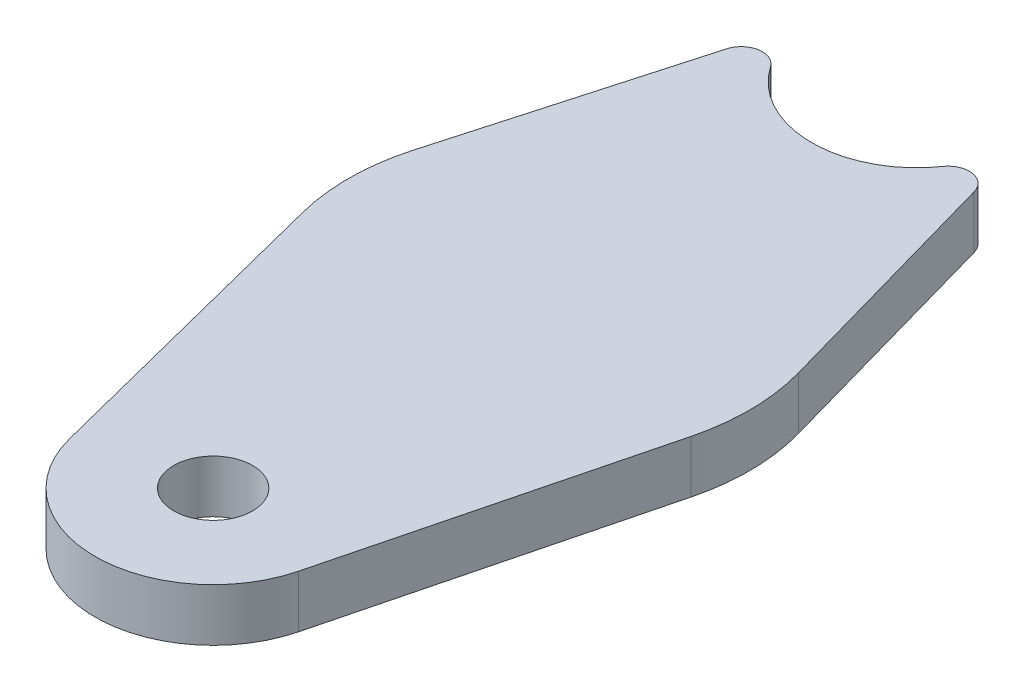
from build123d import *

# Parameters (mm, degrees)
SKETCH13_R              = 4.7625
BOSS_EXTRUDE1_DEPTH     = 6.35
SKETCH14_R              = 12.7
CUT_EXTRUDE1_DEPTH      = 7.35
CUT_EXTRUDE1_DEPTH_BACK = 1
FILLET1_R               = 2.54
FILLET2_R               = 25.4


with BuildPart() as part:
    # Sketch13 → Boss-Extrude1 (new body)
    with BuildSketch(Plane(origin=(0, 0, 0), x_dir=(1, 0, 0), z_dir=(0, 1, 0))):
        with BuildLine():
            Line((12.7, 54.409872551), (25.137792916, 10.286231112))
            Line((25.137792916, 10.286231112), (13.84741683, -34.144859739))
            ThreePointArc((13.84741683, -34.144859739), (0, -44.913595269), (-13.84741683, -34.144859739))
            Line((-13.84741683, -34.144859739), (-25.137792916, 10.286231112))
            Line((-25.137792916, 10.286231112), (-12.7, 54.409872551))
            Line((-12.7, 54.409872551), (12.7, 54.409872551))
        make_face()
        with Locations((0, -30.626095269)):
            Circle(SKETCH13_R, mode=Mode.SUBTRACT)
    extrude(amount=BOSS_EXTRUDE1_DEPTH)

    # Sketch14 → Cut-Extrude1 (cut, two sides)
    with BuildSketch(Plane(origin=(0, 0, 0), x_dir=(1, 0, 0), z_dir=(0, 1, 0))) as cut_extrude1_sk:
        with Locations((0, 54.409872551)):
            Circle(SKETCH14_R)
    extrude(amount=CUT_EXTRUDE1_DEPTH, mode=Mode.SUBTRACT)
    extrude(cut_extrude1_sk.sketch, amount=-CUT_EXTRUDE1_DEPTH_BACK, mode=Mode.SUBTRACT)

    # Fillet1
    fillet1_edges = [part.edges().sort_by_distance(p)[0] for p in [
        (12.7, 3.175, -54.409872551),
        (-12.7, 3.175, -54.409872551),
    ]]
    fillet(fillet1_edges, radius=FILLET1_R)

    # Fillet2
    fillet2_edges = [part.edges().sort_by_distance(p)[0] for p in [
        (25.137792916, 3.175, -10.286231112),
        (-25.137792916, 3.175, -10.286231112),
    ]]
    fillet(fillet2_edges, radius=FILLET2_R)


solid = part.part
